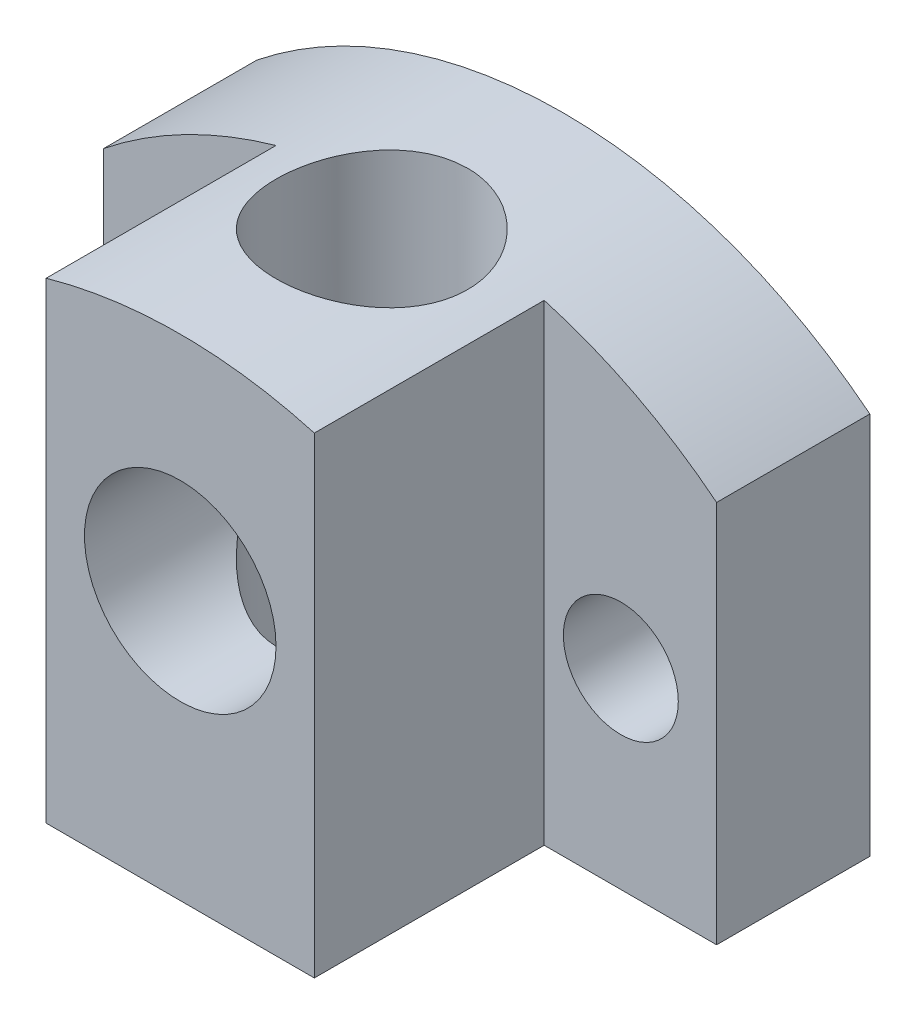
from build123d import *

# Parameters (mm, degrees)
EXTRUDE_START            = -3.462177
EXTRUDE_1_DEPTH          = 40
EXTRUDE_START_2          = 60
EXTRUDE_2_DEPTH          = 60
CUT_EXTRUDE_1_REACH      = 163.234
CUT_EXTRUDE_1_END_RADIUS = 128.062484749
SKETCH_1_R               = 25
CUT_EXTRUDE_2_DEPTH      = 163.48076826
CUT_EXTRUDE_2_DEPTH_BACK = 163.48076826
SKETCH_5_R               = 25
SKETCH_5_R_2             = 15


with BuildPart() as part:
    # 草图2 → 凸台-拉伸1 (new body)
    with BuildSketch(Plane.XY.offset(EXTRUDE_START)):
        with BuildLine():
            Line((-80, 0), (80, 0))
            Line((80, 0), (80, 100))
            ThreePointArc((80, 100), (0, 128.062484749), (-80, 100))
            Line((-80, 100), (-80, 0))
        make_face()
    extrude(amount=-EXTRUDE_1_DEPTH)

    # 草图4 → 凸台-拉伸2 (add)
    with BuildSketch(Plane.XY.offset(-3.46217708).offset(EXTRUDE_START_2)):
        with BuildLine():
            Line((-35, 0), (-35, 123.186849948))
            ThreePointArc((-35, 123.186849948), (0, 128.062484749), (35, 123.186849948))
            Line((35, 123.186849948), (35, 0))
            Line((35, 0), (-35, 0))
        make_face()
    extrude(amount=-EXTRUDE_2_DEPTH)

    # 切除-拉伸1: up to this cylinder (the profile starts inside it)
    cut_extrude_1_end = Plane(origin=(0, 0, 6.537823), z_dir=(0, 0, 1)) * Cylinder(CUT_EXTRUDE_1_END_RADIUS, 583.592969497, mode=Mode.PRIVATE)
    # 草图1 → 切除-拉伸1 (cut, up to the surface)
    with BuildSketch(Plane(origin=(0, 0, 0), x_dir=(1, 0, 0), z_dir=(0, 1, 0)), mode=Mode.PRIVATE) as cut_extrude_1_sk1:
        with Locations(Location((0, -6.53782292, 0), (0, 0, 90))):
            Circle(SKETCH_1_R)
    cut_extrude_1_tool1 = extrude(cut_extrude_1_sk1.sketch, amount=CUT_EXTRUDE_1_REACH, mode=Mode.PRIVATE) & cut_extrude_1_end
    add(cut_extrude_1_tool1.solids().sort_by_distance((0, 0, 6.537823))[0], mode=Mode.SUBTRACT)

    # 草图5 → 切除-拉伸2 (cut, two sides: drawn at the far end of the back side and taken through both)
    with BuildSketch(Plane.XY.offset(-3.46217708).offset(-CUT_EXTRUDE_2_DEPTH_BACK)):
        with Locations((0, 70)):
            Circle(SKETCH_5_R)
        with Locations((-55, 50)):
            Circle(SKETCH_5_R_2)
        with Locations((55, 50)):
            Circle(SKETCH_5_R_2)
    extrude(amount=CUT_EXTRUDE_2_DEPTH + CUT_EXTRUDE_2_DEPTH_BACK, mode=Mode.SUBTRACT)


solid = part.part
